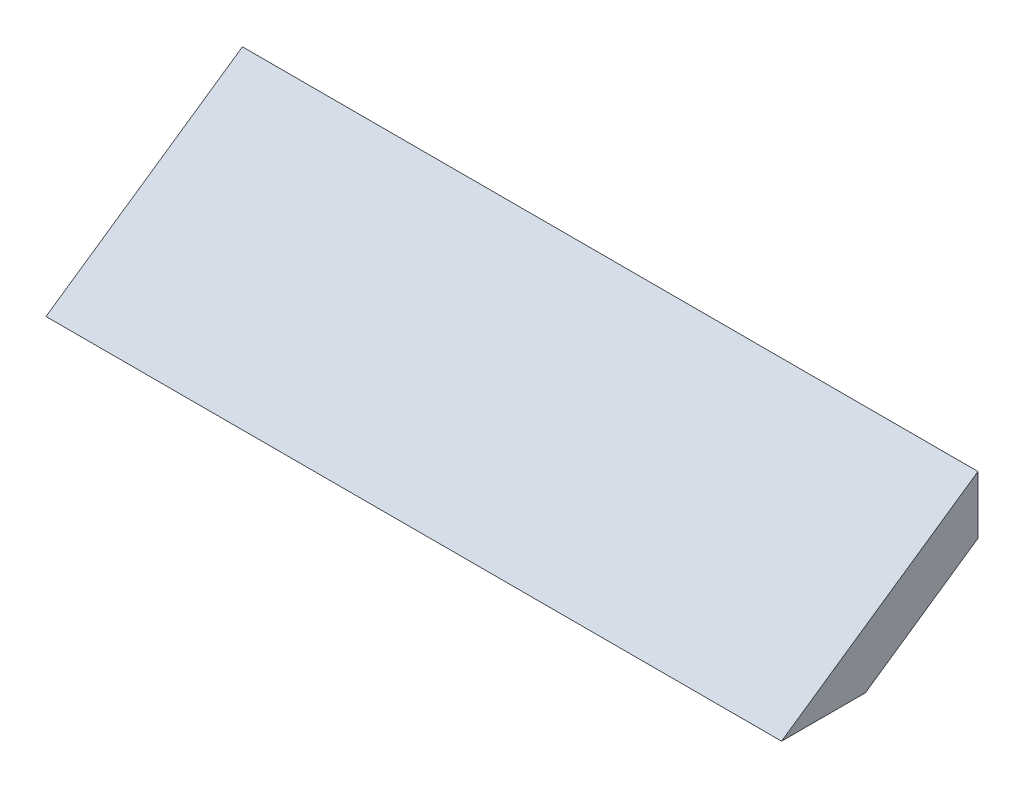
from build123d import *

# Parameters (mm, degrees)
SKETCH1_W          = 1400
SKETCH1_H          = 110
SKETCH3_W          = 241.229259038
SKETCH3_H          = 118.473208867
CUT_EXTRUDE1_DEPTH = 3000
SKETCH4_W          = 263.080499957
SKETCH4_H          = 130.335311081
CUT_EXTRUDE2_DEPTH = 1000


with BuildPart() as part:
    # Sweep2: sweep along a path in Sketch2
    with BuildLine(Plane(origin=(0, 0, 0), x_dir=(0, 0, -1), z_dir=(1, 0, 0))) as sweep2_path:
        Line((0, -52.72397822), (-373.826634648, -310.359400666))
    # Sketch1 → Sweep2 (sweep)
    with BuildSketch(Plane.XY):
        Rectangle(SKETCH1_W, SKETCH1_H)
    sweep(path=sweep2_path.line)

    # Sketch3 → Cut-Extrude1 (cut)
    with BuildSketch(Plane(origin=(0, 0, 0), x_dir=(0, 0, -1), z_dir=(1, 0, 0))):
        with Locations((-253.212005129, -261.87202688)):
            Rectangle(SKETCH3_W, SKETCH3_H)
    extrude(amount=CUT_EXTRUDE1_DEPTH, mode=Mode.SUBTRACT)

    # Sketch4 → Cut-Extrude2 (cut)
    with BuildSketch(Plane(origin=(0, 0, 0), x_dir=(0, 0, -1), z_dir=(1, 0, 0))):
        with Locations((-242.28638467, -267.803077986)):
            Rectangle(SKETCH4_W, SKETCH4_H)
    extrude(amount=-CUT_EXTRUDE2_DEPTH, mode=Mode.SUBTRACT)


solid = part.part
